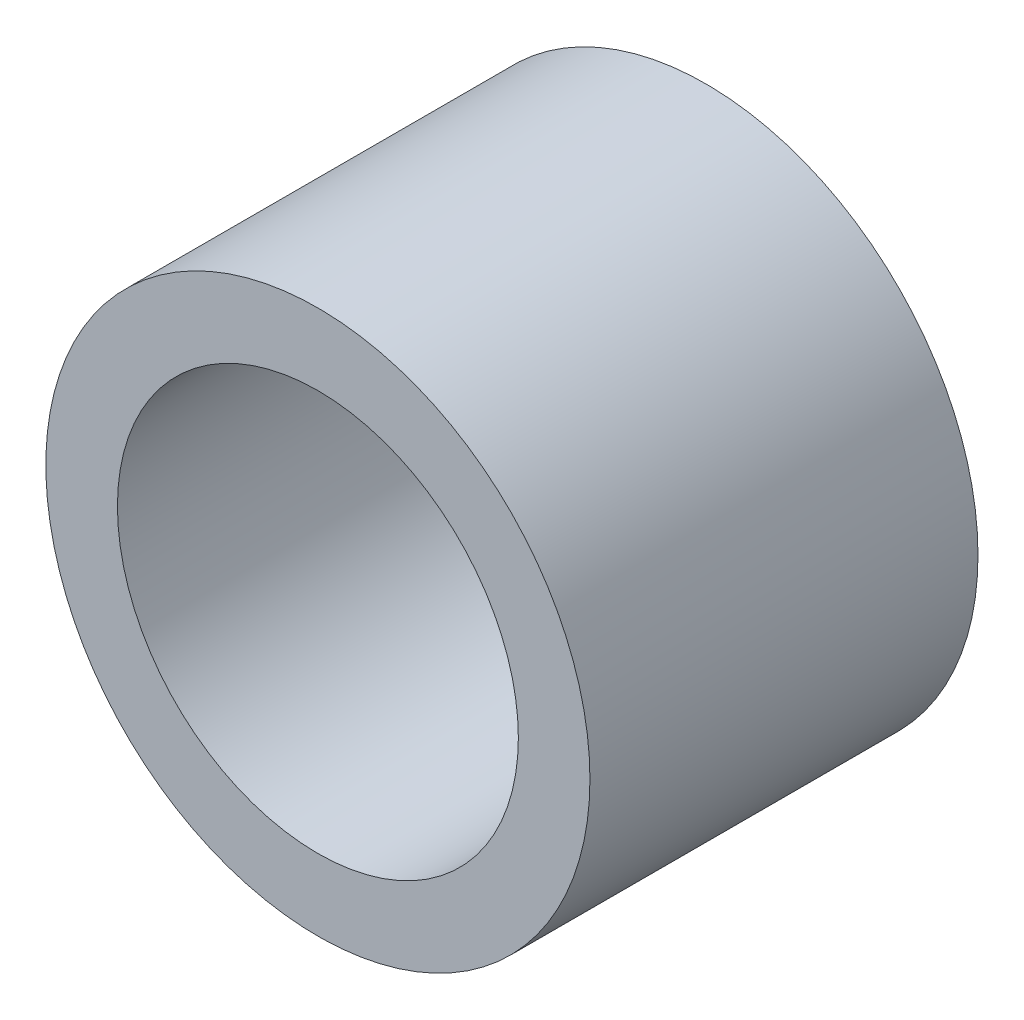
from build123d import *

# Parameters (mm, degrees)
SKETCH1_R           = 4.826
SKETCH1_R_2         = 3.556
BOSS_EXTRUDE1_DEPTH = 6.8834


with BuildPart() as part:
    # Sketch1 → Boss-Extrude1 (new body)
    with BuildSketch(Plane.XY):
        Circle(SKETCH1_R)
        Circle(SKETCH1_R_2, mode=Mode.SUBTRACT)
    extrude(amount=BOSS_EXTRUDE1_DEPTH)


solid = part.part
